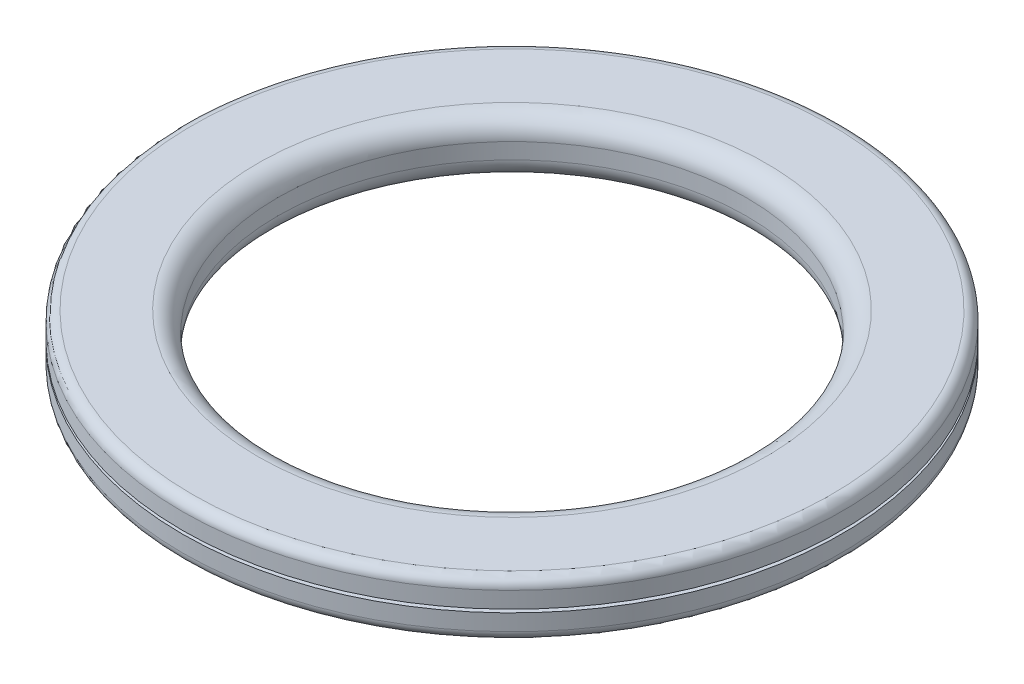
from build123d import *

# Parameters (mm, degrees)
SKETCH1_R           = 8.3
SKETCH1_R_2         = 5.9
BOSS_EXTRUDE1_DEPTH = 1.4
SKETCH2_W           = 1.295074367
SKETCH2_H           = 0.08
SKETCH3_R           = 7.141016866
SKETCH3_R_2         = 7.061016866
CUT_EXTRUDE1_DEPTH  = 0.3
FILLET1_R           = 0.5
FILLET2_R           = 0.25


with BuildPart() as part:
    # Sketch1 → Boss-Extrude1 (new body)
    with BuildSketch(Plane(origin=(0, 0, 0), x_dir=(1, 0, 0), z_dir=(0, 1, 0))):
        Circle(SKETCH1_R)
        Circle(SKETCH1_R_2, mode=Mode.SUBTRACT)
    extrude(amount=BOSS_EXTRUDE1_DEPTH)

    # Sketch2 → Cut-Revolve1 (revolve, cut)
    with BuildSketch(Plane.XY):
        with Locations((8.00669044, 0.7)):
            Rectangle(SKETCH2_W, SKETCH2_H)
    revolve(axis=Axis((0, 1.4, 0), (0, -1, 0)), mode=Mode.SUBTRACT)

    # Sketch3 → Cut-Extrude1 (cut)
    with BuildSketch(Plane.XZ):
        Circle(SKETCH3_R)
        Circle(SKETCH3_R_2, mode=Mode.SUBTRACT)
    extrude(amount=-CUT_EXTRUDE1_DEPTH, mode=Mode.SUBTRACT)

    # Fillet1
    fillet1_edges = [part.edges().sort_by_distance(p)[0] for p in [
        (-5.9, 0, 0),
        (-5.9, 1.4, 0),
    ]]
    fillet(fillet1_edges, radius=FILLET1_R)

    # Fillet2
    fillet2_edges = [part.edges().sort_by_distance(p)[0] for p in [
        (-8.3, 0, 0),
        (-8.3, 1.4, 0),
    ]]
    fillet(fillet2_edges, radius=FILLET2_R)


solid = part.part
